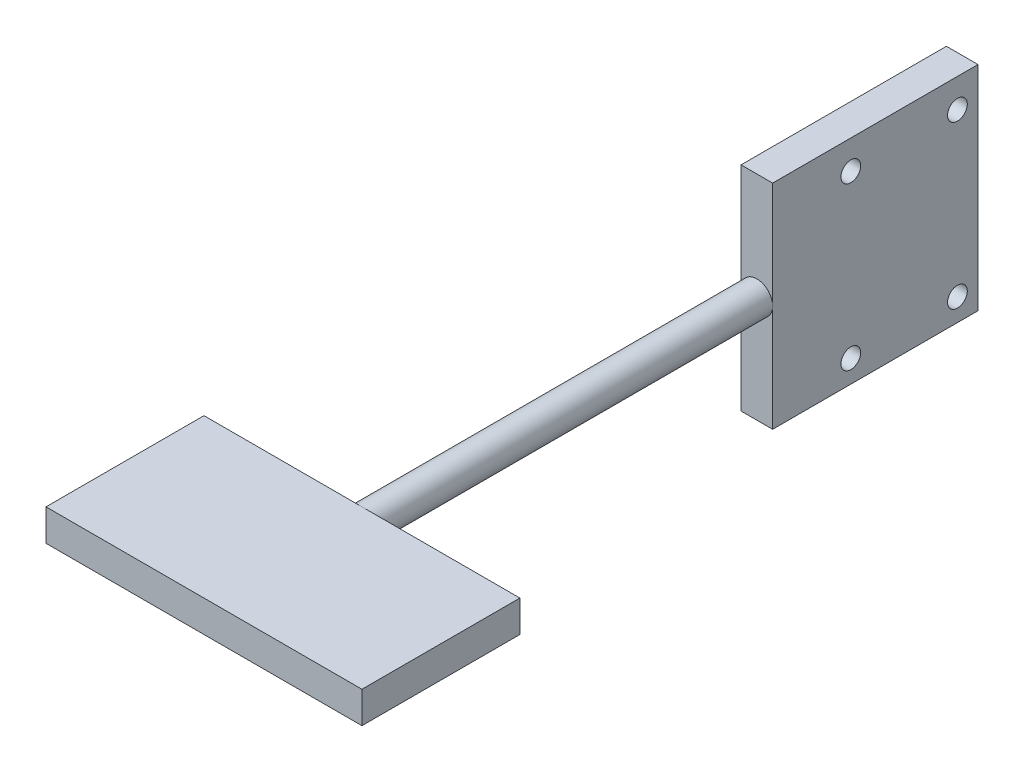
from build123d import *

# Parameters (mm, degrees)
SKETCH1_W           = 40
SKETCH1_H           = 20
BOSS_EXTRUDE1_DEPTH = 4
SKETCH3_R           = 2
BOSS_EXTRUDE3_DEPTH = 50
SKETCH5_W           = 26
SKETCH5_H           = 13.5
BOSS_EXTRUDE4_DEPTH = 2
BOSS_EXTRUDE5_DEPTH = 2
SKETCH7_R           = 1.25
CUT_EXTRUDE1_DEPTH  = 23


with BuildPart() as part:
    # Sketch1 → Boss-Extrude1 (new body)
    with BuildSketch(Plane(origin=(0, 0, 0), x_dir=(1, 0, 0), z_dir=(0, 1, 0))):
        with Locations((7.118644068, 0.169491525)):
            Rectangle(SKETCH1_W, SKETCH1_H)
    extrude(amount=BOSS_EXTRUDE1_DEPTH)

    # Sketch3 → Boss-Extrude3 (add)
    with BuildSketch(Plane(origin=(0, 0, -10.169491525), x_dir=(-1, 0, 0), z_dir=(0, 0, -1))):
        with Locations((-7.118644068, 2)):
            Circle(SKETCH3_R)
    extrude(amount=BOSS_EXTRUDE3_DEPTH)

    # Sketch5 → Boss-Extrude4 (add)
    with BuildSketch(Plane(origin=(7.118644068, 0, 0), x_dir=(0, 0, -1), z_dir=(1, 0, 0))):
        with Locations((73.169491525, 8.75)):
            Rectangle(SKETCH5_W, SKETCH5_H)
        with Locations((73.169491525, -4.75)):
            Rectangle(SKETCH5_W, SKETCH5_H)
    extrude(amount=BOSS_EXTRUDE4_DEPTH)

    # Sketch6 → Boss-Extrude5 (add)
    with BuildSketch(Plane.ZY.offset(-7.118644068)):
        Polygon((-60.169491525, -11.5), (-60.169491525, 0), (-60.169491525, 4), (-60.169491525, 15.5), (-86.169491525, 15.5), (-86.169491525, -11.5), align=None)
    extrude(amount=BOSS_EXTRUDE5_DEPTH)

    # Sketch7 → Cut-Extrude1 (cut, through all)
    with BuildSketch(Plane.ZY.offset(-5.118644068)):
        with Locations((-83.564955349, -8.654979701)):
            Circle(SKETCH7_R)
        with Locations((-70.064955349, 11.845020299)):
            Circle(SKETCH7_R)
        with Locations((-70.064955349, -8.654979701)):
            Circle(SKETCH7_R)
        with Locations((-83.564955349, 11.845020299)):
            Circle(SKETCH7_R)
    extrude(amount=-CUT_EXTRUDE1_DEPTH, mode=Mode.SUBTRACT)


solid = part.part
